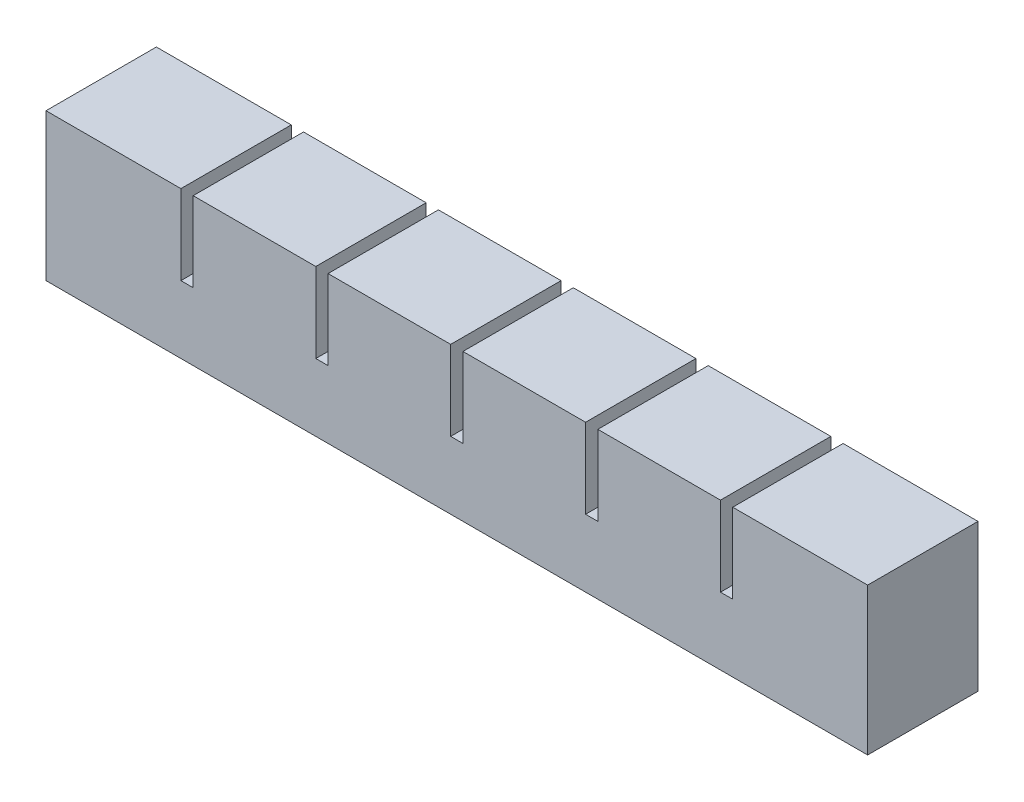
from build123d import *

# Parameters (mm, degrees)
SKETCH1_W           = 20
SKETCH1_H           = 18
BOSS_EXTRUDE1_DEPTH = 18
SKETCH2_W           = 10
SKETCH2_H           = 8
CUT_EXTRUDE1_DEPTH  = 13
SKETCH3_W           = 18
SKETCH3_H           = 5
BOSS_EXTRUDE2_DEPTH = 2
LPATTERN1_COUNT     = 6
LPATTERN1_PITCH     = 22
SKETCH4_W           = 18
SKETCH4_H           = 13
BOSS_EXTRUDE3_DEPTH = 2
SKETCH5_W           = 18
SKETCH5_H           = 18
BOSS_EXTRUDE4_DEPTH = 2
SKETCH6_W           = 120
SKETCH6_H           = 2
CUT_EXTRUDE2_DEPTH  = 2
SKETCH7_W           = 134
SKETCH7_H           = 18
BOSS_EXTRUDE5_DEPTH = 6


with BuildPart() as part:
    # Sketch1 → Boss-Extrude1 (new body)
    with BuildSketch(Plane.XY):
        with Locations((10, 9)):
            Rectangle(SKETCH1_W, SKETCH1_H)
    extrude(amount=BOSS_EXTRUDE1_DEPTH)

    # Sketch2 → Cut-Extrude1 (cut)
    with BuildSketch(Plane.XZ):
        with Locations((10, 9)):
            Rectangle(SKETCH2_W, SKETCH2_H)
    extrude(amount=-CUT_EXTRUDE1_DEPTH, mode=Mode.SUBTRACT)

    # Sketch3 → Boss-Extrude2 (add)
    with BuildSketch(Plane(origin=(20, 0, 0), x_dir=(0, 0, -1), z_dir=(1, 0, 0))):
        with Locations((-9, 2.5)):
            Rectangle(SKETCH3_W, SKETCH3_H)
    extrude(amount=BOSS_EXTRUDE2_DEPTH)


with BuildPart() as lpattern1_1:
    # LPattern1: pattern copy
    add(part.part.moved(Location(Vector(1, 0, 0) * (1 * LPATTERN1_PITCH))))


with BuildPart() as lpattern1_2:
    # LPattern1: pattern copy
    add(part.part.moved(Location(Vector(1, 0, 0) * (2 * LPATTERN1_PITCH))))


with BuildPart() as lpattern1_3:
    # LPattern1: pattern copy
    add(part.part.moved(Location(Vector(1, 0, 0) * (3 * LPATTERN1_PITCH))))


with BuildPart() as lpattern1_4:
    # LPattern1: pattern copy
    add(part.part.moved(Location(Vector(1, 0, 0) * (4 * LPATTERN1_PITCH))))


with BuildPart() as lpattern1_5:
    # LPattern1: pattern copy
    add(part.part.moved(Location(Vector(1, 0, 0) * (5 * LPATTERN1_PITCH))))


with BuildPart() as lpattern1_1_1:
    add(lpattern1_1.part)

    # Combine1: union part, LPattern1_3, LPattern1_4, LPattern1_5, LPattern1_2
    add(part.part)
    add(lpattern1_3.part)
    add(lpattern1_4.part)
    add(lpattern1_5.part)
    add(lpattern1_2.part)

    # Sketch4 → Boss-Extrude3 (add)
    with BuildSketch(Plane(origin=(130, 0, 0), x_dir=(0, 0, -1), z_dir=(1, 0, 0))):
        with Locations((-9, 11.5)):
            Rectangle(SKETCH4_W, SKETCH4_H)
    extrude(amount=BOSS_EXTRUDE3_DEPTH)

    # Sketch5 → Boss-Extrude4 (add)
    with BuildSketch(Plane.ZY):
        with Locations((9, 9)):
            Rectangle(SKETCH5_W, SKETCH5_H)
    extrude(amount=BOSS_EXTRUDE4_DEPTH)

    # Sketch6 → Cut-Extrude2 (cut)
    with BuildSketch(Plane(origin=(0, 0, 0), x_dir=(-1, 0, 0), z_dir=(0, -1, 0))):
        with Locations((-65, -9)):
            Rectangle(SKETCH6_W, SKETCH6_H)
    extrude(amount=-CUT_EXTRUDE2_DEPTH, mode=Mode.SUBTRACT)

    # Sketch7 → Boss-Extrude5 (add)
    with BuildSketch(Plane(origin=(0, 0, 0), x_dir=(-1, 0, 0), z_dir=(0, -1, 0))):
        with Locations((-65, -9)):
            Rectangle(SKETCH7_W, SKETCH7_H)
    extrude(amount=BOSS_EXTRUDE5_DEPTH)


solid = lpattern1_1_1.part
